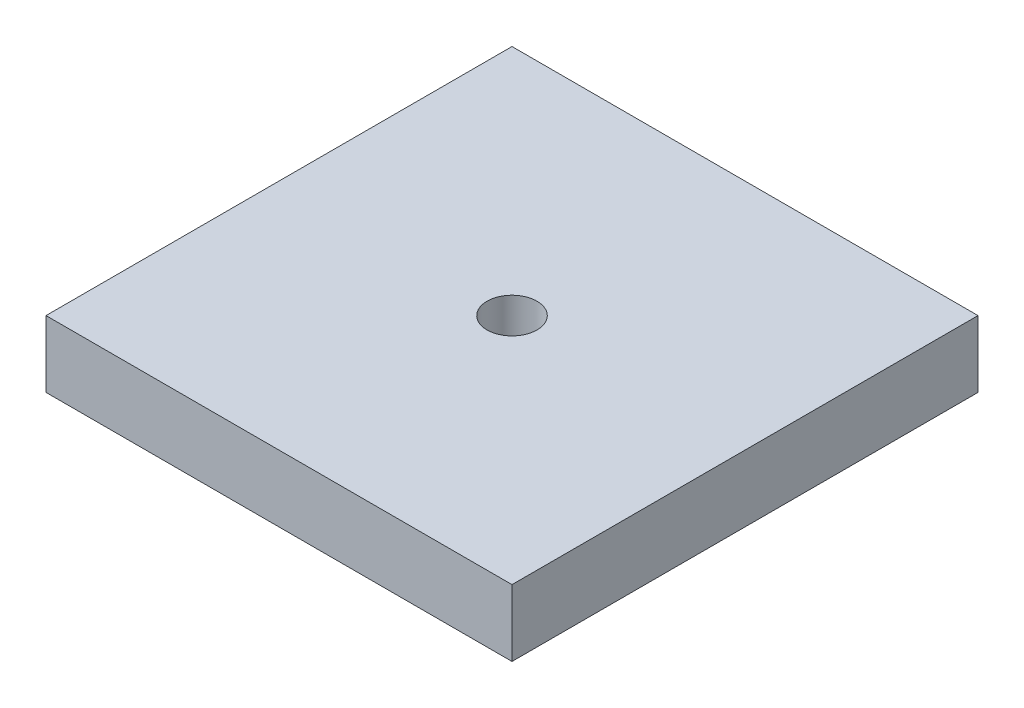
from build123d import *

# Parameters (mm, degrees)
SKETCH1_W           = 11.2
SKETCH1_H           = 11.2
BOSS_EXTRUDE1_DEPTH = 1.6
SKETCH2_R           = 0.6
CUT_EXTRUDE1_DEPTH  = 5


with BuildPart() as part:
    # Sketch1 → Boss-Extrude1 (new body)
    with BuildSketch(Plane(origin=(0, 0, 0), x_dir=(1, 0, 0), z_dir=(0, 1, 0))):
        with Locations((5.6, 5.6)):
            Rectangle(SKETCH1_W, SKETCH1_H)
    extrude(amount=BOSS_EXTRUDE1_DEPTH)

    # Sketch2 → Cut-Extrude1 (cut)
    with BuildSketch(Plane(origin=(0, 1.6, 0), x_dir=(1, 0, 0), z_dir=(0, 1, 0))):
        with Locations((5.6, 5.6)):
            Circle(SKETCH2_R)
    extrude(amount=-CUT_EXTRUDE1_DEPTH, mode=Mode.SUBTRACT)


solid = part.part
